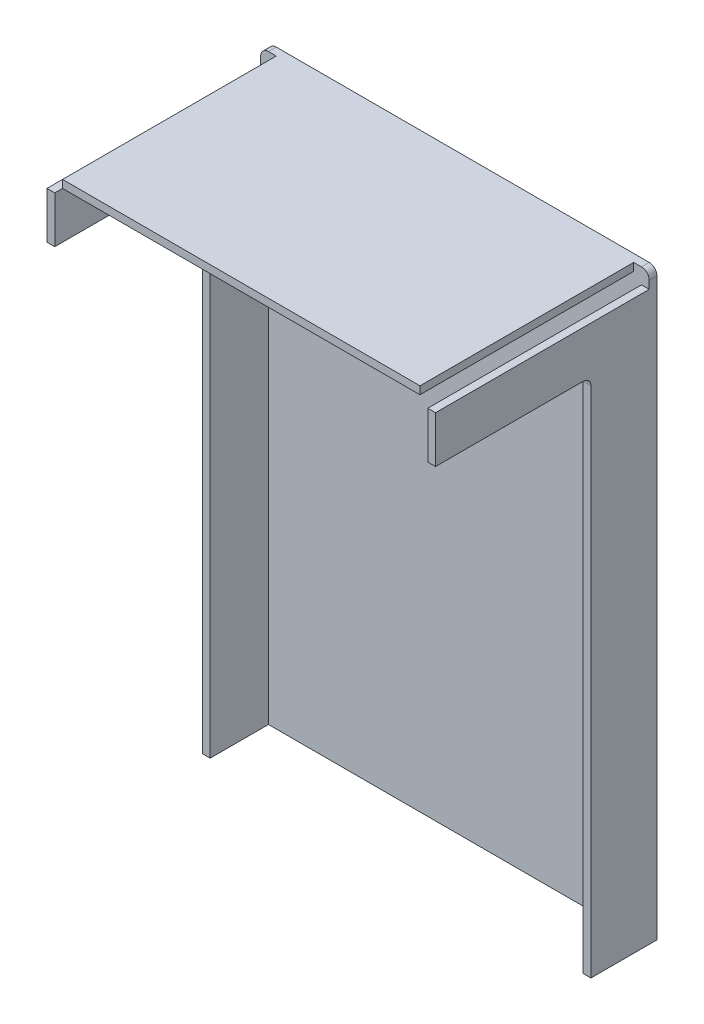
from build123d import *

# Parameters (mm, degrees)
SKETCH1_W           = 127
SKETCH1_H           = 190.5
BOSS_EXTRUDE1_DEPTH = 2.54
SKETCH3_W           = 2.54
SKETCH3_H           = 185.42
SKETCH3_W_2         = 116.84
SKETCH3_H_2         = 2.54
BOSS_EXTRUDE2_DEPTH = 19.05
SKETCH4_W           = 2.54
SKETCH4_H           = 15.24
SKETCH4_W_2         = 116.84
SKETCH4_H_2         = 2.54
BOSS_EXTRUDE3_DEPTH = 50.8
FILLET2_R           = 2.54


with BuildPart() as part:
    # Sketch1 → Boss-Extrude1 (new body)
    with BuildSketch(Plane.XY):
        with Locations((63.5, 95.25)):
            Rectangle(SKETCH1_W, SKETCH1_H)
    extrude(amount=BOSS_EXTRUDE1_DEPTH)

    # Sketch3 → Boss-Extrude2 (add)
    with BuildSketch(Plane.XY.offset(2.54)):
        with Locations((1.27, 92.71)):
            Rectangle(SKETCH3_W, SKETCH3_H)
        with Locations((63.5, 189.23)):
            Rectangle(SKETCH3_W_2, SKETCH3_H_2)
        with Locations((125.73, 92.71)):
            Rectangle(SKETCH3_W, SKETCH3_H)
    extrude(amount=BOSS_EXTRUDE2_DEPTH)

    # Sketch4 → Boss-Extrude3 (add)
    with BuildSketch(Plane.XY.offset(21.59)):
        with Locations((1.27, 177.8)):
            Rectangle(SKETCH4_W, SKETCH4_H)
        with Locations((63.5, 189.23)):
            Rectangle(SKETCH4_W_2, SKETCH4_H_2)
        with Locations((125.73, 177.8)):
            Rectangle(SKETCH4_W, SKETCH4_H)
    extrude(amount=BOSS_EXTRUDE3_DEPTH)

    # Fillet2
    fillet2_edges = [part.edges().sort_by_distance(p)[0] for p in [
        (1.27, 170.18, 21.59),
        (0, 190.5, 1.27),
        (125.73, 170.18, 21.59),
        (127, 190.5, 1.27),
    ]]
    fillet(fillet2_edges, radius=FILLET2_R)


solid = part.part
